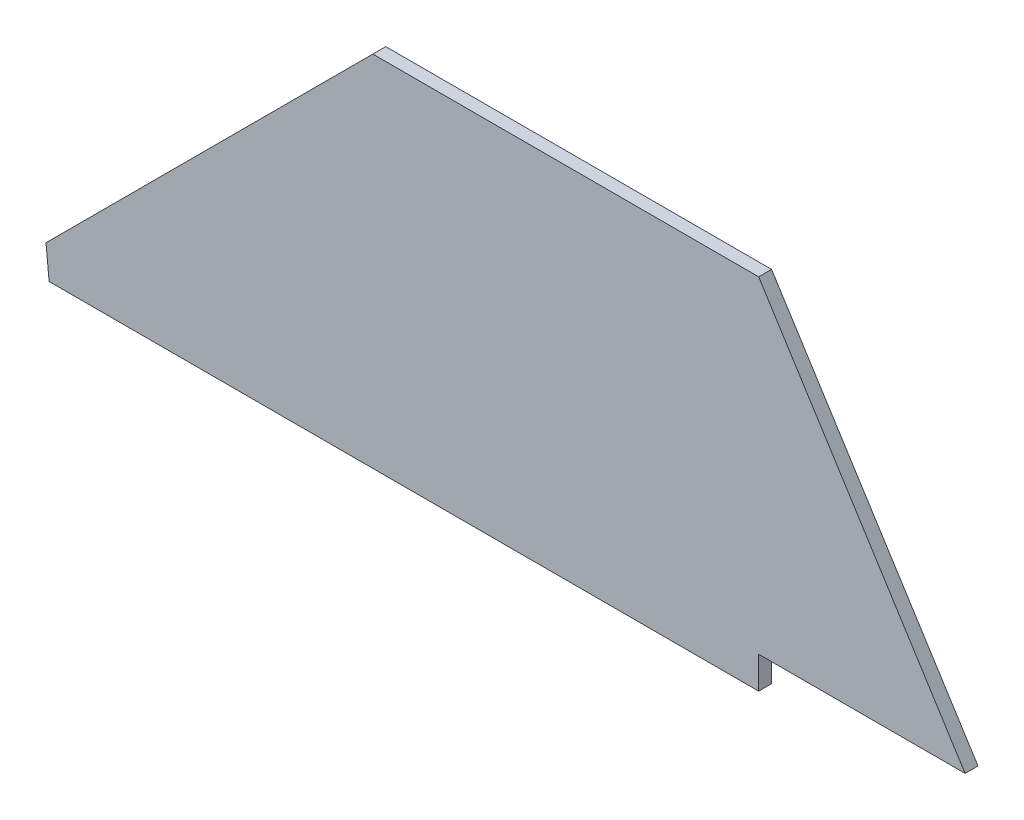
from build123d import *

# Parameters (mm, degrees)
BOSS_EXTRUDE1_DEPTH = 3.175


with BuildPart() as part:
    # Sketch1 → Boss-Extrude1 (new body)
    with BuildSketch(Plane.XY):
        Polygon((0, 0), (174.625, 0), (174.625, 7.874), (225.425, 7.874), (174.625, 88.306736835), (79.672429238, 88.306736835), (-0.760307597, 7.874), align=None)
    extrude(amount=BOSS_EXTRUDE1_DEPTH)


solid = part.part
